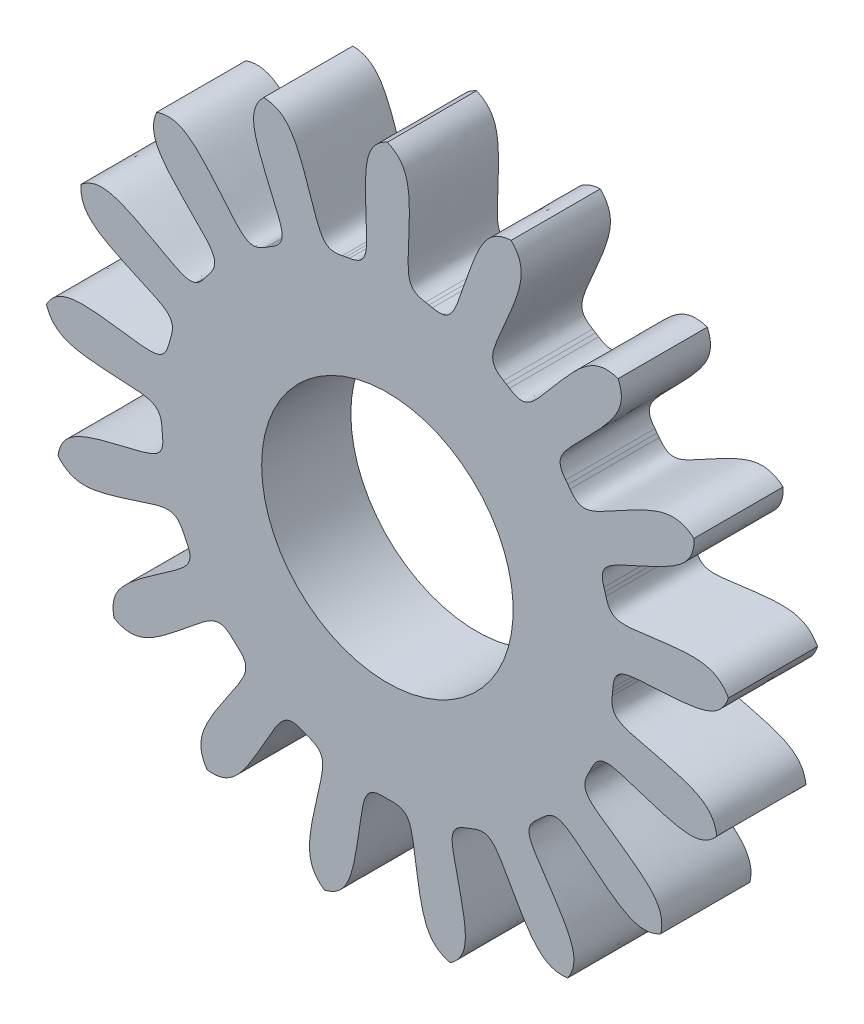
from build123d import *

# Parameters (mm, degrees)
BOSS_EXTRUDE1_17_TEETH_DEPTH = 0.5
CUT_EXTRUDE1_REACH           = 2.5
SKETCH2_R                    = 0.705


with BuildPart() as part:
    # Sketch1 → Boss-Extrude1 (17 teeth) (new body)
    with BuildSketch(Plane.XY):
        with BuildLine():
            Line((0.213306555, 1.249929723), (0.232994389, 1.24640989))
            Line((0.232994389, 1.24640989), (0.252624257, 1.242579971))
            add(Edge.make_bspline(
                [(0.693583999, 1.79034668), (0.578557942, 1.784358492), (0.516328, 1.691711636), (0.377605509, 1.288453607), (0.358256996, 1.220124862), (0.252624257, 1.242579971)],
                knots=[0, 0, 0, 0, 0.427279663, 0.527279663, 1, 1, 1, 1], degree=3))
            add(Edge.make_bspline(
                [(0.693583999, 1.79034668), (0.774555064, 1.708428802), (0.758127763, 1.598037909), (0.588971743, 1.206569891), (0.55723769, 1.14303933), (0.650429135, 1.08846954)],
                knots=[0, 0, 0, 0, 0.427279663, 0.527279663, 1, 1, 1, 1], degree=3))
            Line((0.650429135, 1.08846954), (0.667515983, 1.078075328))
            Line((0.667515983, 1.078075328), (0.684436763, 1.067412909))
            add(Edge.make_bspline(
                [(1.293495636, 1.418897121), (1.184073849, 1.454865506), (1.092578252, 1.390954933), (0.817549779, 1.065040364), (0.774824638, 1.008315196), (0.684436763, 1.067412909)],
                knots=[0, 0, 0, 0, 0.427279663, 0.527279663, 1, 1, 1, 1], degree=3))
            add(Edge.make_bspline(
                [(1.293495636, 1.418897121), (1.339406755, 1.313260852), (1.284210962, 1.216258635), (0.985063112, 0.912331783), (0.932522103, 0.864554961), (0.999707656, 0.780005514)],
                knots=[0, 0, 0, 0, 0.427279663, 0.527279663, 1, 1, 1, 1], degree=3))
            Line((0.999707656, 0.780005514), (1.011885844, 0.764140719))
            Line((1.011885844, 0.764140719), (1.023812292, 0.748085818))
            add(Edge.make_bspline(
                [(1.718713519, 0.855817643), (1.629674021, 0.928884872), (1.521269756, 0.90234206), (1.14707942, 0.697787518), (1.086747919, 0.660326976), (1.023812292, 0.748085818)],
                knots=[0, 0, 0, 0, 0.427279663, 0.527279663, 1, 1, 1, 1], degree=3))
            add(Edge.make_bspline(
                [(1.718713519, 0.855817643), (1.723364141, 0.740729747), (1.636854355, 0.670216894), (1.24811625, 0.494878211), (1.181864239, 0.469307654), (1.213970118, 0.366197422)],
                knots=[0, 0, 0, 0, 0.427279663, 0.527279663, 1, 1, 1, 1], degree=3))
            Line((1.213970118, 0.366197422), (1.219594916, 0.347004671))
            Line((1.219594916, 0.347004671), (1.224916298, 0.327725592))
            add(Edge.make_bspline(
                [(1.911809618, 0.17715525), (1.855177686, 0.277453188), (1.74450535, 0.291862891), (1.32168963, 0.236294602), (1.251899871, 0.223157938), (1.224916298, 0.327725592)],
                knots=[0, 0, 0, 0, 0.427279663, 0.527279663, 1, 1, 1, 1], degree=3))
            add(Edge.make_bspline(
                [(1.911809618, 0.17715525), (1.87457165, 0.068158985), (1.768431497, 0.033658647), (1.342604371, 0.010588595), (1.271589061, 0.010677747), (1.264279189, -0.097067662)],
                knots=[0, 0, 0, 0, 0.427279663, 0.527279663, 1, 1, 1, 1], degree=3))
            Line((1.264279189, -0.097067662), (1.262590936, -0.11699628))
            Line((1.262590936, -0.11699628), (1.26058857, -0.136895791))
            add(Edge.make_bspline(
                [(1.846705235, -0.525432941), (1.830129325, -0.411450085), (1.73213583, -0.358033979), (1.317798331, -0.25711121), (1.24797581, -0.244149815), (1.26058857, -0.136895791)],
                knots=[0, 0, 0, 0, 0.427279663, 0.527279663, 1, 1, 1, 1], degree=3))
            add(Edge.make_bspline(
                [(1.846705235, -0.525432941), (1.772607871, -0.613617026), (1.661172166, -0.607445387), (1.255766333, -0.475131069), (1.189578734, -0.449394248), (1.14384035, -0.54722322)],
                knots=[0, 0, 0, 0, 0.427279663, 0.527279663, 1, 1, 1, 1], degree=3))
            Line((1.14384035, -0.54722322), (1.135067053, -0.565196235))
            Line((1.135067053, -0.565196235), (1.126011371, -0.583028638))
            add(Edge.make_bspline(
                [(1.532193076, -1.157058502), (1.557911858, -1.044784745), (1.485831768, -0.959576376), (1.135931066, -0.715792728), (1.075505699, -0.678483783), (1.126011371, -0.583028638)],
                knots=[0, 0, 0, 0, 0.427279663, 0.527279663, 1, 1, 1, 1], degree=3))
            add(Edge.make_bspline(
                [(1.532193076, -1.157058502), (1.431243577, -1.212520657), (1.329562329, -1.166510555), (0.999330093, -0.89668165), (0.946909207, -0.84877306), (0.868919534, -0.92347325)],
                knots=[0, 0, 0, 0, 0.427279663, 0.527279663, 1, 1, 1, 1], degree=3))
            Line((0.868919534, -0.92347325), (0.854246076, -0.937063307))
            Line((0.854246076, -0.937063307), (0.839360096, -0.950420238))
            add(Edge.make_bspline(
                [(1.010749753, -1.632416901), (1.075289761, -1.537015436), (1.038857892, -1.431522666), (0.800650016, -1.077802472), (0.757782585, -1.021184757), (0.839360096, -0.950420238)],
                knots=[0, 0, 0, 0, 0.427279663, 0.527279663, 1, 1, 1, 1], degree=3))
            add(Edge.make_bspline(
                [(1.010749753, -1.632416901), (0.896581906, -1.647666655), (0.818387732, -1.568032009), (0.607928787, -1.197130405), (0.576354345, -1.133520367), (0.476646319, -1.175003101)],
                knots=[0, 0, 0, 0, 0.427279663, 0.527279663, 1, 1, 1, 1], degree=3))
            Line((0.476646319, -1.175003101), (0.458054433, -1.182374787))
            Line((0.458054433, -1.182374787), (0.43934859, -1.189452318))
            add(Edge.make_bspline(
                [(0.352799074, -1.887308351), (0.447443824, -1.821663675), (0.451580502, -1.710133888), (0.357236744, -1.29424902), (0.337716733, -1.22596907), (0.43934859, -1.189452318)],
                knots=[0, 0, 0, 0, 0.427279663, 0.527279663, 1, 1, 1, 1], degree=3))
            add(Edge.make_bspline(
                [(0.352799074, -1.887308351), (0.240831881, -1.860286141), (0.196685338, -1.757782052), (0.134423329, -1.335900066), (0.127959634, -1.265179468), (0.019999378, -1.267842271)],
                knots=[0, 0, 0, 0, 0.427279663, 0.527279663, 1, 1, 1, 1], degree=3))
            Line((0.019999378, -1.267842271), (0, -1.268))
            Line((0, -1.268), (-0.019999378, -1.267842271))
            add(Edge.make_bspline(
                [(-0.352799074, -1.887308351), (-0.240831881, -1.860286141), (-0.196685338, -1.757782052), (-0.134423329, -1.335900066), (-0.127959634, -1.265179468), (-0.019999378, -1.267842271)],
                knots=[0, 0, 0, 0, 0.427279663, 0.527279663, 1, 1, 1, 1], degree=3))
            add(Edge.make_bspline(
                [(-0.352799074, -1.887308351), (-0.447443824, -1.821663675), (-0.451580502, -1.710133888), (-0.357236744, -1.29424902), (-0.337716733, -1.22596907), (-0.43934859, -1.189452318)],
                knots=[0, 0, 0, 0, 0.427279663, 0.527279663, 1, 1, 1, 1], degree=3))
            Line((-0.43934859, -1.189452318), (-0.458054433, -1.182374787))
            Line((-0.458054433, -1.182374787), (-0.476646319, -1.175003101))
            add(Edge.make_bspline(
                [(-1.010749753, -1.632416901), (-0.896581906, -1.647666655), (-0.818387732, -1.568032009), (-0.607928787, -1.197130405), (-0.576354345, -1.133520367), (-0.476646319, -1.175003101)],
                knots=[0, 0, 0, 0, 0.427279663, 0.527279663, 1, 1, 1, 1], degree=3))
            add(Edge.make_bspline(
                [(-1.010749753, -1.632416901), (-1.075289761, -1.537015436), (-1.038857892, -1.431522666), (-0.800650016, -1.077802472), (-0.757782585, -1.021184757), (-0.839360096, -0.950420238)],
                knots=[0, 0, 0, 0, 0.427279663, 0.527279663, 1, 1, 1, 1], degree=3))
            Line((-0.839360096, -0.950420238), (-0.854246076, -0.937063307))
            Line((-0.854246076, -0.937063307), (-0.868919534, -0.92347325))
            add(Edge.make_bspline(
                [(-1.532193076, -1.157058502), (-1.431243577, -1.212520657), (-1.329562329, -1.166510555), (-0.999330093, -0.89668165), (-0.946909207, -0.84877306), (-0.868919534, -0.92347325)],
                knots=[0, 0, 0, 0, 0.427279663, 0.527279663, 1, 1, 1, 1], degree=3))
            add(Edge.make_bspline(
                [(-1.532193076, -1.157058502), (-1.557911858, -1.044784745), (-1.485831768, -0.959576376), (-1.135931066, -0.715792728), (-1.075505699, -0.678483783), (-1.126011371, -0.583028638)],
                knots=[0, 0, 0, 0, 0.427279663, 0.527279663, 1, 1, 1, 1], degree=3))
            Line((-1.126011371, -0.583028638), (-1.135067053, -0.565196235))
            Line((-1.135067053, -0.565196235), (-1.14384035, -0.54722322))
            add(Edge.make_bspline(
                [(-1.846705235, -0.525432941), (-1.772607871, -0.613617026), (-1.661172166, -0.607445387), (-1.255766333, -0.475131069), (-1.189578734, -0.449394248), (-1.14384035, -0.54722322)],
                knots=[0, 0, 0, 0, 0.427279663, 0.527279663, 1, 1, 1, 1], degree=3))
            add(Edge.make_bspline(
                [(-1.846705235, -0.525432941), (-1.830129325, -0.411450085), (-1.73213583, -0.358033979), (-1.317798331, -0.25711121), (-1.24797581, -0.244149815), (-1.26058857, -0.136895791)],
                knots=[0, 0, 0, 0, 0.427279663, 0.527279663, 1, 1, 1, 1], degree=3))
            Line((-1.26058857, -0.136895791), (-1.262590936, -0.11699628))
            Line((-1.262590936, -0.11699628), (-1.264279189, -0.097067662))
            add(Edge.make_bspline(
                [(-1.911809618, 0.17715525), (-1.87457165, 0.068158985), (-1.768431497, 0.033658647), (-1.342604371, 0.010588595), (-1.271589061, 0.010677747), (-1.264279189, -0.097067662)],
                knots=[0, 0, 0, 0, 0.427279663, 0.527279663, 1, 1, 1, 1], degree=3))
            add(Edge.make_bspline(
                [(-1.911809618, 0.17715525), (-1.855177686, 0.277453188), (-1.74450535, 0.291862891), (-1.32168963, 0.236294602), (-1.251899871, 0.223157938), (-1.224916298, 0.327725592)],
                knots=[0, 0, 0, 0, 0.427279663, 0.527279663, 1, 1, 1, 1], degree=3))
            Line((-1.224916298, 0.327725592), (-1.219594916, 0.347004671))
            Line((-1.219594916, 0.347004671), (-1.213970118, 0.366197422))
            add(Edge.make_bspline(
                [(-1.718713519, 0.855817643), (-1.723364141, 0.740729747), (-1.636854355, 0.670216894), (-1.24811625, 0.494878211), (-1.181864239, 0.469307654), (-1.213970118, 0.366197422)],
                knots=[0, 0, 0, 0, 0.427279663, 0.527279663, 1, 1, 1, 1], degree=3))
            add(Edge.make_bspline(
                [(-1.718713519, 0.855817643), (-1.629674021, 0.928884872), (-1.521269756, 0.90234206), (-1.14707942, 0.697787518), (-1.086747919, 0.660326976), (-1.023812292, 0.748085818)],
                knots=[0, 0, 0, 0, 0.427279663, 0.527279663, 1, 1, 1, 1], degree=3))
            Line((-1.023812292, 0.748085818), (-1.011885844, 0.764140719))
            Line((-1.011885844, 0.764140719), (-0.999707656, 0.780005514))
            add(Edge.make_bspline(
                [(-1.293495636, 1.418897121), (-1.339406755, 1.313260852), (-1.284210962, 1.216258635), (-0.985063112, 0.912331783), (-0.932522103, 0.864554961), (-0.999707656, 0.780005514)],
                knots=[0, 0, 0, 0, 0.427279663, 0.527279663, 1, 1, 1, 1], degree=3))
            add(Edge.make_bspline(
                [(-1.293495636, 1.418897121), (-1.184073849, 1.454865506), (-1.092578252, 1.390954933), (-0.817549779, 1.065040364), (-0.774824638, 1.008315196), (-0.684436763, 1.067412909)],
                knots=[0, 0, 0, 0, 0.427279663, 0.527279663, 1, 1, 1, 1], degree=3))
            Line((-0.684436763, 1.067412909), (-0.667515983, 1.078075328))
            Line((-0.667515983, 1.078075328), (-0.650429135, 1.08846954))
            add(Edge.make_bspline(
                [(-0.693583999, 1.79034668), (-0.774555064, 1.708428802), (-0.758127763, 1.598037909), (-0.588971743, 1.206569891), (-0.55723769, 1.14303933), (-0.650429135, 1.08846954)],
                knots=[0, 0, 0, 0, 0.427279663, 0.527279663, 1, 1, 1, 1], degree=3))
            add(Edge.make_bspline(
                [(-0.693583999, 1.79034668), (-0.578557942, 1.784358492), (-0.516328, 1.691711636), (-0.377605509, 1.288453607), (-0.358256996, 1.220124862), (-0.252624257, 1.242579971)],
                knots=[0, 0, 0, 0, 0.427279663, 0.527279663, 1, 1, 1, 1], degree=3))
            Line((-0.252624257, 1.242579971), (-0.232994389, 1.24640989))
            Line((-0.232994389, 1.24640989), (-0.213306555, 1.249929723))
            add(Edge.make_bspline(
                [(0, 1.92), (-0.10509542, 1.872863976), (-0.129655208, 1.763993308), (-0.113336477, 1.33785405), (-0.106695239, 1.267149904), (-0.213306555, 1.249929723)],
                knots=[0, 0, 0, 0, 0.427279663, 0.527279663, 1, 1, 1, 1], degree=3))
            add(Edge.make_bspline(
                [(0, 1.92), (0.10509542, 1.872863976), (0.129655208, 1.763993308), (0.113336477, 1.33785405), (0.106695239, 1.267149904), (0.213306555, 1.249929723)],
                knots=[0, 0, 0, 0, 0.427279663, 0.527279663, 1, 1, 1, 1], degree=3))
        make_face()
    extrude(amount=BOSS_EXTRUDE1_17_TEETH_DEPTH)

    # Sketch2 → Cut-Extrude1 (cut, up to next)
    with BuildSketch(Plane.XY, mode=Mode.PRIVATE) as cut_extrude1_sk1:
        Circle(SKETCH2_R)
    cut_extrude1_tool1 = extrude(cut_extrude1_sk1.sketch, amount=CUT_EXTRUDE1_REACH, mode=Mode.PRIVATE) & part.part
    add(cut_extrude1_tool1.solids().sort_by_distance((0, 0, 0))[0], mode=Mode.SUBTRACT)


solid = part.part
